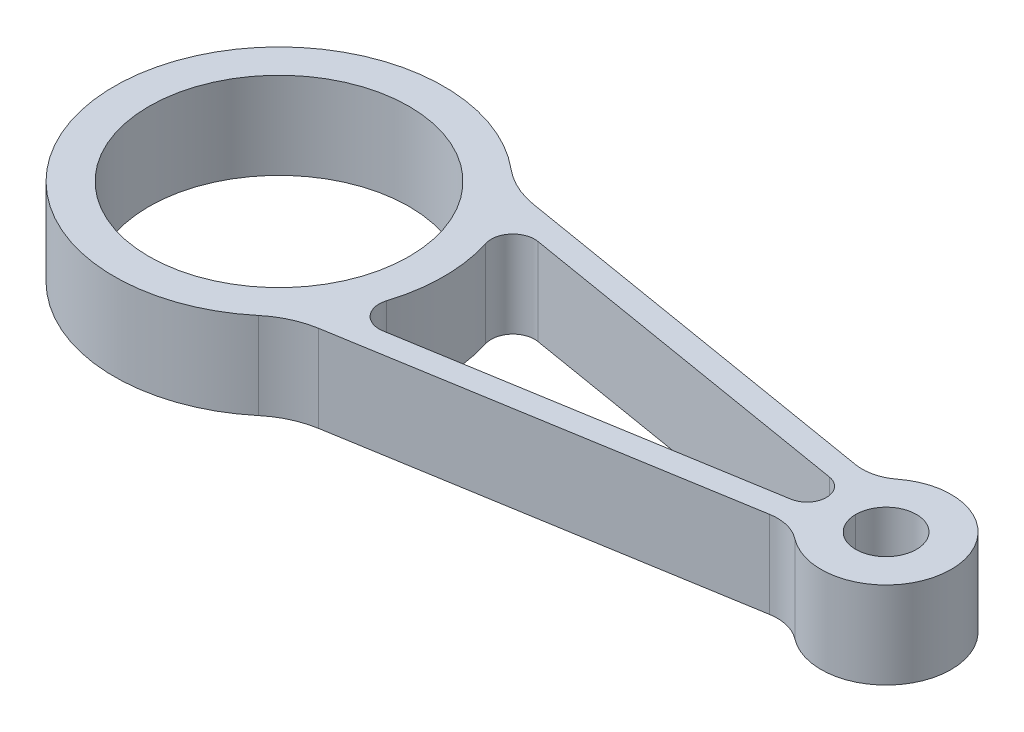
from build123d import *

# Parameters (mm, degrees)
SKETCH1_R           = 30
SKETCH1_R_2         = 7
BOSS_EXTRUDE1_DEPTH = 10
FILLET1_R           = 20
FILLET2_R           = 10
CUT_EXTRUDE1_DEPTH  = 21


with BuildPart() as part:
    # Sketch1 → Boss-Extrude1 (new body, symmetric)
    with BuildSketch(Plane(origin=(0, 0, 0), x_dir=(1, 0, 0), z_dir=(0, 1, 0))):
        with BuildLine():
            Line((27.935473676, 25.760615491), (128.063755469, 9.084385863))
            ThreePointArc((128.063755469, 9.084385863), (155, 0), (128.063755469, -9.084385863))
            Line((128.063755469, -9.084385863), (27.935473676, -25.760615491))
            ThreePointArc((27.935473676, -25.760615491), (-38, 0), (27.935473676, 25.760615491))
        make_face()
        Circle(SKETCH1_R, mode=Mode.SUBTRACT)
        with Locations((140, 0)):
            Circle(SKETCH1_R_2, mode=Mode.SUBTRACT)
    extrude(amount=BOSS_EXTRUDE1_DEPTH, both=True)

    # Fillet1
    fillet1_edges = [part.edges().sort_by_distance(p)[0] for p in [
        (27.935473676, 0, -25.760615491),
        (27.935473676, 0, 25.760615491),
    ]]
    fillet(fillet1_edges, radius=FILLET1_R)

    # Fillet2
    fillet2_edges = [part.edges().sort_by_distance(p)[0] for p in [
        (128.063755469, 0, -9.084385863),
        (128.063755469, 0, 9.084385863),
    ]]
    fillet(fillet2_edges, radius=FILLET2_R)

    # Sketch2 → Cut-Extrude1 (cut, through all)
    with BuildSketch(Plane(origin=(0, 10, 0), x_dir=(1, 0, 0), z_dir=(0, 1, 0))):
        with BuildLine():
            Line((41.828554558, 17.870982725), (122.478416149, 4.438857582))
            ThreePointArc((122.478416149, 4.438857582), (126.239130435, 0), (122.478416149, -4.438857582))
            Line((122.478416149, -4.438857582), (41.828554558, -17.870982725))
            ThreePointArc((41.828554558, -17.870982725), (37.231968897, -16.217361812), (36.238855523, -11.43439331))
            ThreePointArc((36.238855523, -11.43439331), (38, 0), (36.238855523, 11.43439331))
            ThreePointArc((36.238855523, 11.43439331), (37.231968897, 16.217361812), (41.828554558, 17.870982725))
        make_face()
    extrude(amount=-CUT_EXTRUDE1_DEPTH, mode=Mode.SUBTRACT)


solid = part.part
